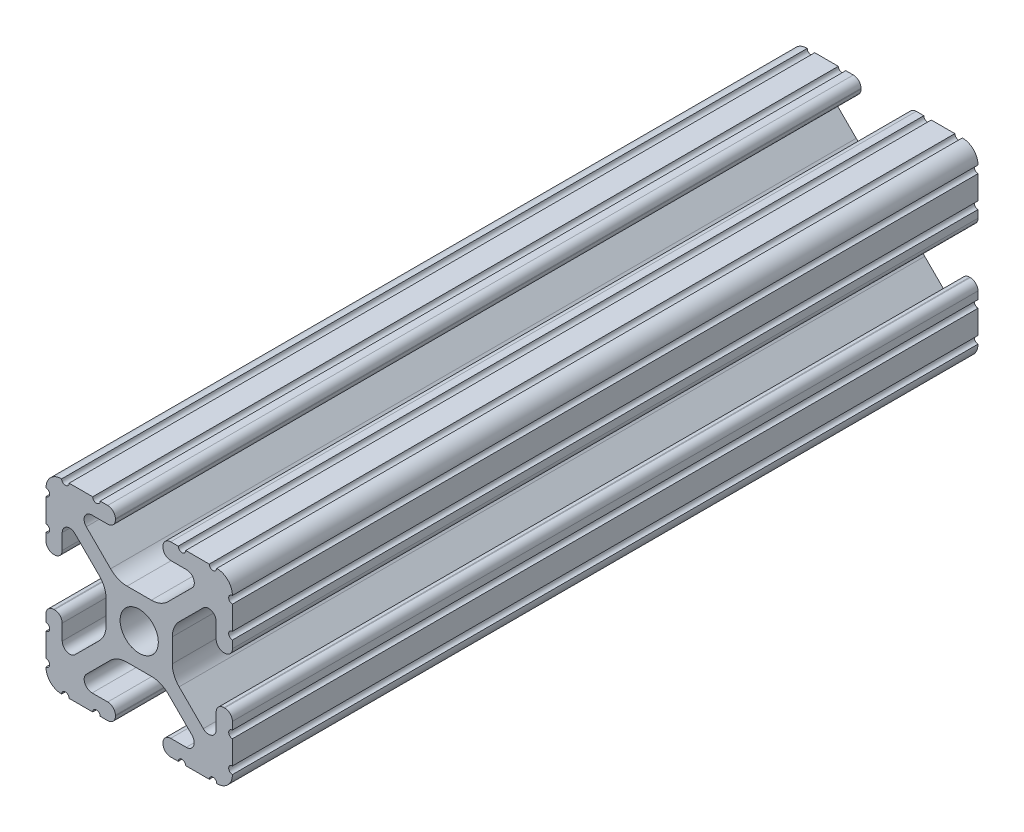
from build123d import *

# Parameters (mm, degrees)
SKETCH1_R           = 2.6035
BOSS_EXTRUDE1_DEPTH = 50.8


with BuildPart() as part:
    # Sketch1 → Boss-Extrude1 (new body, symmetric)
    with BuildSketch(Plane.XY):
        with BuildLine():
            Line((-7.179650497, -8.645192506), (-3.952270251, -5.423690499))
            ThreePointArc((-3.952270251, -5.423690499), (-2.922936451, -4.736929036), (-1.709253557, -4.4958))
            Line((-1.709253557, -4.4958), (1.709253557, -4.4958))
            ThreePointArc((1.709253557, -4.4958), (2.922936451, -4.736929036), (3.952270251, -5.423690499))
            Line((3.952270251, -5.423690499), (7.179650497, -8.645192506))
            ThreePointArc((7.179650497, -8.645192506), (7.41473083, -9.822813117), (6.416408329, -10.4902))
            Line((6.416408329, -10.4902), (4.287512407, -10.4902))
            ThreePointArc((4.287512407, -10.4902), (3.54574862, -10.79744862), (3.2385, -11.539212407))
            Line((3.2385, -11.539212407), (3.2385, -11.650987593))
            ThreePointArc((3.2385, -11.650987593), (3.54574862, -12.39275138), (4.287512407, -12.7))
            Line((4.287512407, -12.7), (5.317126718, -12.7))
            ThreePointArc((5.317126718, -12.7), (5.825126718, -12.192), (6.333126718, -12.7))
            Line((6.333126718, -12.7), (9.550443118, -12.7))
            ThreePointArc((9.550443118, -12.7), (10.058366869, -12.192000006), (10.566443095, -12.699847501))
            ThreePointArc((10.566443095, -12.699847501), (12.082537762, -12.08250727), (12.699846982, -10.566399977))
            ThreePointArc((12.699846982, -10.566399977), (12.192000006, -10.058323491), (12.7, -9.5504))
            Line((12.7, -9.5504), (12.7, -6.3330836))
            ThreePointArc((12.7, -6.3330836), (12.192, -5.8250836), (12.7, -5.3170836))
            Line((12.7, -5.3170836), (12.7, -4.287469289))
            ThreePointArc((12.7, -4.287469289), (12.39275138, -3.545705502), (11.650987593, -3.238456882))
            Line((11.650987593, -3.238456882), (11.539212407, -3.238456882))
            ThreePointArc((11.539212407, -3.238456882), (10.79744862, -3.545705502), (10.4902, -4.287469289))
            Line((10.4902, -4.287469289), (10.4902, -6.402089023))
            ThreePointArc((10.4902, -6.402089023), (9.856505071, -7.351067942), (8.737131347, -7.129408934))
            Line((8.737131347, -7.129408934), (5.441005833, -3.840816462))
            ThreePointArc((5.441005833, -3.840816462), (4.750877967, -2.809883091), (4.5085, -1.593185507))
            Line((4.5085, -1.593185507), (4.5085, 1.593185507))
            ThreePointArc((4.5085, 1.593185507), (4.750877967, 2.809883091), (5.441005833, 3.840816462))
            Line((5.441005833, 3.840816462), (8.737131347, 7.129408934))
            ThreePointArc((8.737131347, 7.129408934), (9.856505071, 7.351067942), (10.4902, 6.402089023))
            Line((10.4902, 6.402089023), (10.4902, 4.287469289))
            ThreePointArc((10.4902, 4.287469289), (10.79744862, 3.545705502), (11.539212407, 3.238456882))
            Line((11.539212407, 3.238456882), (11.650987593, 3.238456882))
            ThreePointArc((11.650987593, 3.238456882), (12.39275138, 3.545705502), (12.7, 4.287469289))
            Line((12.7, 4.287469289), (12.7, 5.3170836))
            ThreePointArc((12.7, 5.3170836), (12.192, 5.8250836), (12.7, 6.3330836))
            Line((12.7, 6.3330836), (12.7, 9.5504))
            ThreePointArc((12.7, 9.5504), (12.192000006, 10.058323491), (12.699846982, 10.566399977))
            ThreePointArc((12.699846982, 10.566399977), (12.082537762, 12.08250727), (10.566443095, 12.699847501))
            ThreePointArc((10.566443095, 12.699847501), (10.058366869, 12.192000006), (9.550443118, 12.7))
            Line((9.550443118, 12.7), (6.333126718, 12.7))
            ThreePointArc((6.333126718, 12.7), (5.825126718, 12.192), (5.317126718, 12.7))
            Line((5.317126718, 12.7), (4.287512407, 12.7))
            ThreePointArc((4.287512407, 12.7), (3.54574862, 12.39275138), (3.2385, 11.650987593))
            Line((3.2385, 11.650987593), (3.2385, 11.539212407))
            ThreePointArc((3.2385, 11.539212407), (3.54574862, 10.79744862), (4.287512407, 10.4902))
            Line((4.287512407, 10.4902), (6.476788598, 10.4902))
            ThreePointArc((6.476788598, 10.4902), (7.432222385, 9.85140422), (7.207036008, 8.724370562))
            Line((7.207036008, 8.724370562), (3.898272566, 5.423169045))
            ThreePointArc((3.898272566, 5.423169045), (2.869120213, 4.736787962), (1.655778399, 4.4958))
            Line((1.655778399, 4.4958), (-1.655778399, 4.4958))
            ThreePointArc((-1.655778399, 4.4958), (-2.869120213, 4.736787962), (-3.898272566, 5.423169045))
            Line((-3.898272566, 5.423169045), (-7.207036008, 8.724370562))
            ThreePointArc((-7.207036008, 8.724370562), (-7.432222385, 9.85140422), (-6.476788598, 10.4902))
            Line((-6.476788598, 10.4902), (-4.287512407, 10.4902))
            ThreePointArc((-4.287512407, 10.4902), (-3.54574862, 10.79744862), (-3.2385, 11.539212407))
            Line((-3.2385, 11.539212407), (-3.2385, 11.650987593))
            ThreePointArc((-3.2385, 11.650987593), (-3.54574862, 12.39275138), (-4.287512407, 12.7))
            Line((-4.287512407, 12.7), (-5.317126718, 12.7))
            ThreePointArc((-5.317126718, 12.7), (-5.825126718, 12.192), (-6.333126718, 12.7))
            Line((-6.333126718, 12.7), (-9.550443118, 12.7))
            ThreePointArc((-9.550443118, 12.7), (-10.058366869, 12.192000006), (-10.566443095, 12.699847501))
            ThreePointArc((-10.566443095, 12.699847501), (-12.082537762, 12.08250727), (-12.699846982, 10.566399977))
            ThreePointArc((-12.699846982, 10.566399977), (-12.192000006, 10.058323491), (-12.7, 9.5504))
            Line((-12.7, 9.5504), (-12.7, 6.3330836))
            ThreePointArc((-12.7, 6.3330836), (-12.192, 5.8250836), (-12.7, 5.3170836))
            Line((-12.7, 5.3170836), (-12.7, 4.287469289))
            ThreePointArc((-12.7, 4.287469289), (-12.39275138, 3.545705502), (-11.650987593, 3.238456882))
            Line((-11.650987593, 3.238456882), (-11.539212407, 3.238456882))
            ThreePointArc((-11.539212407, 3.238456882), (-10.79744862, 3.545705502), (-10.4902, 4.287469289))
            Line((-10.4902, 4.287469289), (-10.4902, 6.402089023))
            ThreePointArc((-10.4902, 6.402089023), (-9.856505071, 7.351067942), (-8.737131347, 7.129408934))
            Line((-8.737131347, 7.129408934), (-5.441005833, 3.840816462))
            ThreePointArc((-5.441005833, 3.840816462), (-4.750877967, 2.809883091), (-4.5085, 1.593185507))
            Line((-4.5085, 1.593185507), (-4.5085, -1.593185507))
            ThreePointArc((-4.5085, -1.593185507), (-4.750877967, -2.809883091), (-5.441005833, -3.840816462))
            Line((-5.441005833, -3.840816462), (-8.737131347, -7.129408934))
            ThreePointArc((-8.737131347, -7.129408934), (-9.856505071, -7.351067942), (-10.4902, -6.402089023))
            Line((-10.4902, -6.402089023), (-10.4902, -4.287469289))
            ThreePointArc((-10.4902, -4.287469289), (-10.79744862, -3.545705502), (-11.539212407, -3.238456882))
            Line((-11.539212407, -3.238456882), (-11.650987593, -3.238456882))
            ThreePointArc((-11.650987593, -3.238456882), (-12.39275138, -3.545705502), (-12.7, -4.287469289))
            Line((-12.7, -4.287469289), (-12.7, -5.3170836))
            ThreePointArc((-12.7, -5.3170836), (-12.192, -5.8250836), (-12.7, -6.3330836))
            Line((-12.7, -6.3330836), (-12.7, -9.5504))
            ThreePointArc((-12.7, -9.5504), (-12.192000006, -10.058323491), (-12.699846982, -10.566399977))
            ThreePointArc((-12.699846982, -10.566399977), (-12.082537762, -12.08250727), (-10.566443095, -12.699847501))
            ThreePointArc((-10.566443095, -12.699847501), (-10.058366869, -12.192000006), (-9.550443118, -12.7))
            Line((-9.550443118, -12.7), (-6.333126718, -12.7))
            ThreePointArc((-6.333126718, -12.7), (-5.825126718, -12.192), (-5.317126718, -12.7))
            Line((-5.317126718, -12.7), (-4.287512407, -12.7))
            ThreePointArc((-4.287512407, -12.7), (-3.54574862, -12.39275138), (-3.2385, -11.650987593))
            Line((-3.2385, -11.650987593), (-3.2385, -11.539212407))
            ThreePointArc((-3.2385, -11.539212407), (-3.54574862, -10.79744862), (-4.287512407, -10.4902))
            Line((-4.287512407, -10.4902), (-6.416408329, -10.4902))
            ThreePointArc((-6.416408329, -10.4902), (-7.41473083, -9.822813117), (-7.179650497, -8.645192506))
        make_face()
        Circle(SKETCH1_R, mode=Mode.SUBTRACT)
    extrude(amount=BOSS_EXTRUDE1_DEPTH, both=True)


solid = part.part
